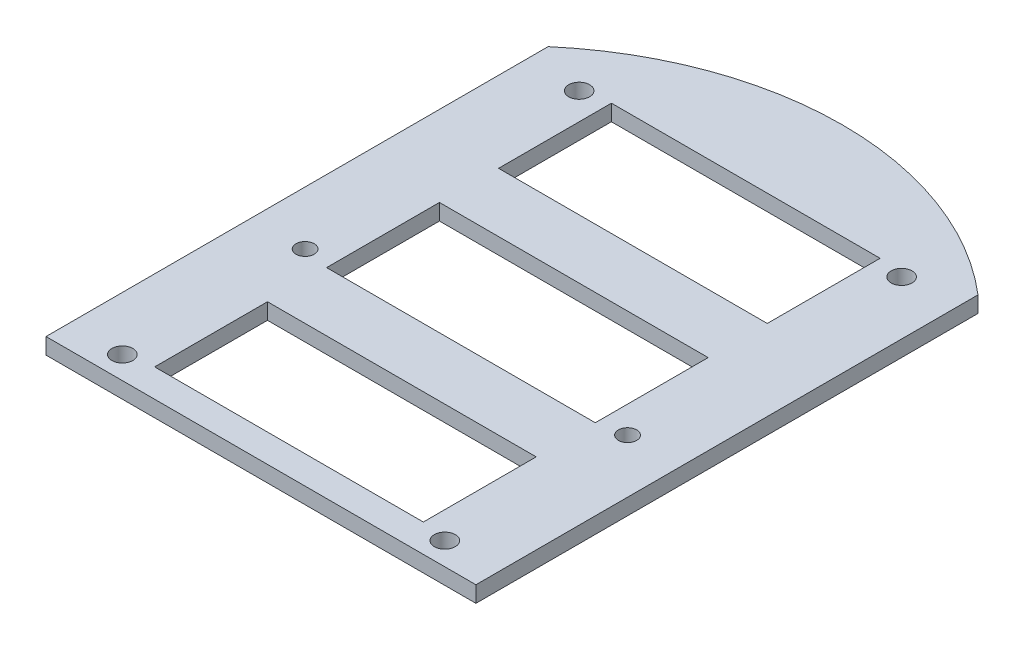
from build123d import *

# Parameters (mm, degrees)
ESQUISSE1_R             = 61.5
BOSS_EXTRU_1_DEPTH      = 3
ESQUISSE3_W             = 30.466369815
ESQUISSE3_H             = 114.600421842
ENL_V_MAT_EXTRU_1_DEPTH = 4
D_GAGEMENT_M31_D        = 3.4
D_GAGEMENT_M3_51_D      = 3.9
ESQUISSE15_W            = 50
ESQUISSE15_H            = 21
ESQUISSE15_W_2          = 80
ESQUISSE15_H_2          = 16.662747472
ENL_V_MAT_EXTRU_2_DEPTH = 4


with BuildPart() as part:
    # Esquisse1 → Boss.-Extru.1 (new body)
    with BuildSketch(Plane(origin=(0, 0, 0), x_dir=(1, 0, 0), z_dir=(0, 1, 0))):
        Circle(ESQUISSE1_R)
    extrude(amount=BOSS_EXTRU_1_DEPTH)

    # Esquisse3 → Enlèv. mat.-Extru.1 (cut, through all)
    with BuildSketch(Plane(origin=(0, 3, 0), x_dir=(1, 0, 0), z_dir=(0, 1, 0))):
        with Locations((-55.233184908, -9.960159363)):
            Rectangle(ESQUISSE3_W, ESQUISSE3_H)
        with Locations((55.233184908, -9.960159363)):
            Rectangle(ESQUISSE3_W, ESQUISSE3_H)
    extrude(amount=-ENL_V_MAT_EXTRU_1_DEPTH, mode=Mode.SUBTRACT)

    # Dégagement M31 (through all)
    with Locations(Plane(origin=(0, 3, 0), x_dir=(1, 0, 0), z_dir=(0, 1, 0))):
        with Locations((-30, -8.5)):
            d_gagement_m31 = Hole(D_GAGEMENT_M31_D / 2)

    # Symétrie1: Dégagement M31 across plane
    add(d_gagement_m31.mirror(Plane.ZY), mode=Mode.SUBTRACT)

    # Dégagement M3.51 (through all)
    with Locations(Plane(origin=(0, 3, 0), x_dir=(1, 0, 0), z_dir=(0, 1, 0))):
        with Locations((-30, 42.5), (30, 42.5), (30, -42.5), (-30, -42.5)):
            Hole(D_GAGEMENT_M3_51_D / 2)

    # Esquisse15 → Enlèv. mat.-Extru.2 (cut, through all)
    with BuildSketch(Plane(origin=(0, 3, 0), x_dir=(1, 0, 0), z_dir=(0, 1, 0))):
        with Locations((0, 33)):
            Rectangle(ESQUISSE15_W, ESQUISSE15_H)
        with Locations((0, -55.045932494)):
            Rectangle(ESQUISSE15_W_2, ESQUISSE15_H_2)
        with Locations((0, -31)):
            Rectangle(ESQUISSE15_W, ESQUISSE15_H)
        with Locations((0, 1)):
            Rectangle(ESQUISSE15_W, ESQUISSE15_H)
    extrude(amount=-ENL_V_MAT_EXTRU_2_DEPTH, mode=Mode.SUBTRACT)


solid = part.part
